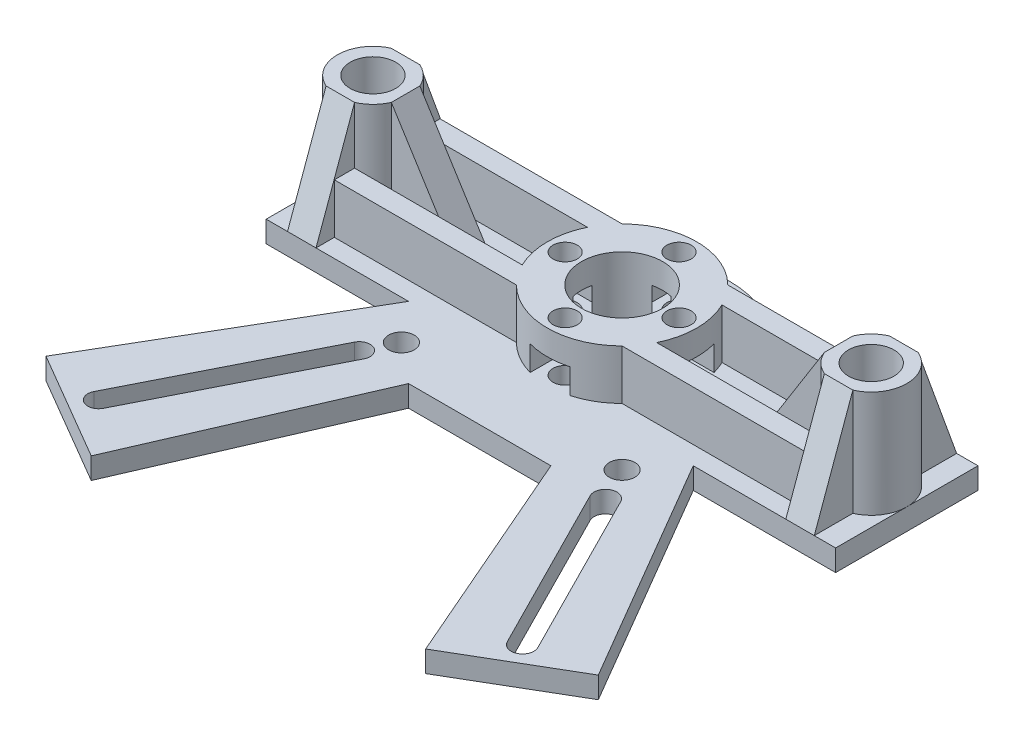
from build123d import *

# Parameters (mm, degrees)
SKETCH_1_R          = 3.2
SKETCH_1_R_2        = 1.8
SKETCH_1_R_3        = 5.7
SKETCH_1_R_4        = 1.7
EXTRUDE_1_DEPTH     = 3
SKETCH_2_R          = 10.5
EXTRUDE_2_DEPTH     = 7
SKETCH_4_R          = 1.7
CUT_EXTRUDE_1_DEPTH = 7
CUT_EXTRUDE_2_DEPTH = 3.5
SKETCH_6_R          = 5.7
CUT_EXTRUDE_3_DEPTH = 20
SKETCH_7_R          = 5
SKETCH_7_R_2        = 3.2
EXTRUDE_3_DEPTH     = 15
SKETCH_8_W          = 10
SKETCH_8_H          = 4
SKETCH_8_W_2        = 4
SKETCH_8_H_2        = 6
EXTRUDE_4_DEPTH     = 15
CUT_EXTRUDE_4_DEPTH = 15
CUT_EXTRUDE_5_DEPTH = 15
CUT_EXTRUDE_6_DEPTH = 15
SKETCH_12_W         = 25.575378798
SKETCH_12_H         = 2.842045507
EXTRUDE_5_DEPTH     = 7


with BuildPart() as part:
    # 草图1 → 凸台-拉伸1 (new body)
    with BuildSketch(Plane(origin=(0, 0, 0), x_dir=(1, 0, 0), z_dir=(0, 1, 0))):
        with BuildLine():
            Line((-35.081832586, -10), (-40, -10))
            Line((-40, -10), (-40, 10))
            Line((-40, 10), (-11.180339887, 10))
            ThreePointArc((-11.180339887, 10), (0, 15), (11.180339887, 10))
            Line((11.180339887, 10), (40, 10))
            Line((40, 10), (40, -10))
            Line((40, -10), (20, -10))
            Line((20, -10), (38.795982487, -42.134997854))
            Line((38.795982487, -42.134997854), (23.493176713, -51.085714784))
            Line((23.493176713, -51.085714784), (10.00055485, -20.000324527))
            Line((10.00055485, -20.000324527), (-9.99944515, -20.000324527))
            Line((-9.99944515, -20.000324527), (-23.493239928, -51.085714784))
            Line((-23.493239928, -51.085714784), (-38.79573581, -42.1354119))
            Line((-38.79573581, -42.1354119), (-20, -10))
            Line((-20, -10), (-35.081832586, -10))
        make_face()
        with Locations((35, 0)):
            Circle(SKETCH_1_R, mode=Mode.SUBTRACT)
        with Locations((-15.5, -15.5)):
            Circle(SKETCH_1_R_2, mode=Mode.SUBTRACT)
        with Locations((15.5, -15.5)):
            Circle(SKETCH_1_R_2, mode=Mode.SUBTRACT)
        with Locations((-35, 0)):
            Circle(SKETCH_1_R, mode=Mode.SUBTRACT)
        Circle(SKETCH_1_R_3, mode=Mode.SUBTRACT)
        with Locations((-8, 0)):
            Circle(SKETCH_1_R_4, mode=Mode.SUBTRACT)
        with Locations((0, 8)):
            Circle(SKETCH_1_R_4, mode=Mode.SUBTRACT)
        with Locations((8, 0)):
            Circle(SKETCH_1_R_4, mode=Mode.SUBTRACT)
        with Locations((0, -8)):
            Circle(SKETCH_1_R_4, mode=Mode.SUBTRACT)
        with BuildLine():
            Line((-16.131862345, -20.121977189), (-28.419219954, -44.445930008))
            ThreePointArc((-28.419219954, -44.445930008), (-30.461319047, -45.117305053), (-31.132694091, -43.07520596))
            Line((-31.132694091, -43.07520596), (-18.845336482, -18.75125314))
            ThreePointArc((-18.845336482, -18.75125314), (-16.803237389, -18.079878096), (-16.131862345, -20.121977189))
        make_face(mode=Mode.SUBTRACT)
        with BuildLine():
            Line((19.251434516, -19.436615165), (31.203359651, -43.037711333))
            ThreePointArc((31.203359651, -43.037711333), (30.498813674, -45.187970612), (28.348554395, -44.483424635))
            Line((28.348554395, -44.483424635), (16.39662926, -20.882328467))
            ThreePointArc((16.39662926, -20.882328467), (17.101175237, -18.732069188), (19.251434516, -19.436615165))
        make_face(mode=Mode.SUBTRACT)
    extrude(amount=EXTRUDE_1_DEPTH)

    # 草图2 → 凸台-拉伸2 (add)
    with BuildSketch(Plane(origin=(0, 3, 0), x_dir=(1, 0, 0), z_dir=(0, 1, 0))):
        Circle(SKETCH_2_R)
    extrude(amount=EXTRUDE_2_DEPTH)

    # 草图4 → 切除-拉伸1 (cut)
    with BuildSketch(Plane.XZ.offset(-3)):
        with Locations((0, -8)):
            Circle(SKETCH_4_R)
        with Locations((-8, 0)):
            Circle(SKETCH_4_R)
        with Locations((8, 0)):
            Circle(SKETCH_4_R)
        with Locations((0, 8)):
            Circle(SKETCH_4_R)
    extrude(amount=-CUT_EXTRUDE_1_DEPTH, mode=Mode.SUBTRACT)

    # 草图5 → 切除-拉伸2 (cut)
    with BuildSketch(Plane(origin=(0, 3, 0), x_dir=(1, 0, 0), z_dir=(0, 1, 0))):
        Polygon((-4.766838493, 0), (-6.383419246, 2.8), (-11.233161507, 2.8), (-11.233161507, -2.8), (-6.383419246, -2.8), align=None)
        Polygon((4.766838493, 0), (6.383419246, -2.8), (11.233161507, -2.8), (11.233161507, 2.8), (6.383419246, 2.8), align=None)
        Polygon((-2.8, 11.233161507), (-2.8, 6.383419246), (0, 4.766838493), (2.8, 6.383419246), (2.8, 11.233161507), align=None)
        Polygon((0, -4.766838493), (-2.8, -6.383419246), (-2.8, -11.233161507), (2.8, -11.233161507), (2.8, -6.383419246), align=None)
    extrude(amount=CUT_EXTRUDE_2_DEPTH, mode=Mode.SUBTRACT)

    # 草图6 → 切除-拉伸3 (cut)
    with BuildSketch(Plane.XZ.offset(-3)):
        Circle(SKETCH_6_R)
    extrude(amount=-CUT_EXTRUDE_3_DEPTH, mode=Mode.SUBTRACT)

    # 草图7 → 凸台-拉伸3 (add)
    with BuildSketch(Plane(origin=(0, 3, 0), x_dir=(1, 0, 0), z_dir=(0, 1, 0))):
        with Locations((-35, 0)):
            Circle(SKETCH_7_R)
        with Locations((-35, 0)):
            Circle(SKETCH_7_R_2, mode=Mode.SUBTRACT)
        with Locations((35, 0)):
            Circle(SKETCH_7_R)
        with Locations((35, 0)):
            Circle(SKETCH_7_R_2, mode=Mode.SUBTRACT)
    extrude(amount=EXTRUDE_3_DEPTH)

    # 草图8 → 凸台-拉伸4 (add)
    with BuildSketch(Plane(origin=(0, 3, 0), x_dir=(1, 0, 0), z_dir=(0, 1, 0))):
        with Locations((-26, 0)):
            Rectangle(SKETCH_8_W, SKETCH_8_H)
        with Locations((-35, 7)):
            Rectangle(SKETCH_8_W_2, SKETCH_8_H_2)
        with Locations((-35, -7)):
            Rectangle(SKETCH_8_W_2, SKETCH_8_H_2)
        with Locations((26, 0)):
            Rectangle(SKETCH_8_W, SKETCH_8_H)
        with Locations((35, 7)):
            Rectangle(SKETCH_8_W_2, SKETCH_8_H_2)
        with Locations((35, -7)):
            Rectangle(SKETCH_8_W_2, SKETCH_8_H_2)
    extrude(amount=EXTRUDE_4_DEPTH)

    # 草图9 → 切除-拉伸4 (cut)
    with BuildSketch(Plane.XY.offset(2)):
        Polygon((-30.417424305, 18), (-21, 3), (-21, 18), align=None)
        Polygon((21, 3), (30.417424305, 18), (21, 18), align=None)
    extrude(amount=-CUT_EXTRUDE_4_DEPTH, mode=Mode.SUBTRACT)

    # 草图10 → 切除-拉伸5 (cut)
    with BuildSketch(Plane.ZY.offset(-33)):
        Polygon((-4.582575695, 18), (-10, 3), (-10, 18), align=None)
        Polygon((4.582575695, 18), (10, 18), (10, 3), align=None)
    extrude(amount=-CUT_EXTRUDE_5_DEPTH, mode=Mode.SUBTRACT)

    # 草图11 → 切除-拉伸6 (cut)
    with BuildSketch(Plane(origin=(-33, 0, 0), x_dir=(0, 0, -1), z_dir=(1, 0, 0))):
        Polygon((-4.582575695, 18), (-10, 3), (-10, 18), align=None)
        Polygon((4.582575695, 18), (10, 3), (10, 18), align=None)
    extrude(amount=-CUT_EXTRUDE_6_DEPTH, mode=Mode.SUBTRACT)

    # 草图12 → 凸台-拉伸5 (add)
    with BuildSketch(Plane(origin=(0, 3, 0), x_dir=(1, 0, 0), z_dir=(0, 1, 0))):
        with Locations((-20.212310601, -6.003598449)):
            Rectangle(SKETCH_12_W, SKETCH_12_H)
        with Locations((-20.212310601, 6.003598449)):
            Rectangle(SKETCH_12_W, SKETCH_12_H)
        with Locations((20.212310601, 6.003598449)):
            Rectangle(SKETCH_12_W, SKETCH_12_H)
        with Locations((20.212310601, -6.003598449)):
            Rectangle(SKETCH_12_W, SKETCH_12_H)
    extrude(amount=EXTRUDE_5_DEPTH)


solid = part.part
